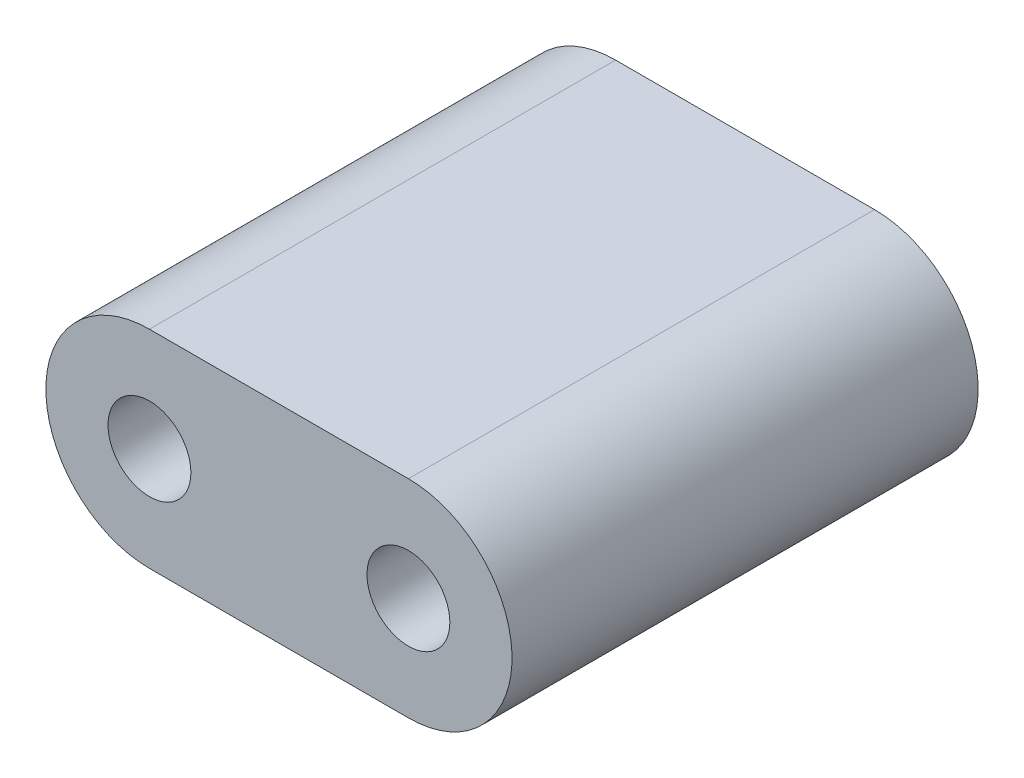
from build123d import *

# Parameters (mm, degrees)
SKETCH1_R           = 1.6
BOSS_EXTRUDE1_DEPTH = 18


with BuildPart() as part:
    # Sketch1 → Boss-Extrude1 (new body)
    with BuildSketch(Plane.XY):
        with BuildLine():
            Line((-5, 4), (5, 4))
            ThreePointArc((5, 4), (9, 0), (5, -4))
            Line((5, -4), (-5, -4))
            ThreePointArc((-5, -4), (-9, 0), (-5, 4))
        make_face()
        with Locations((-5, 0)):
            Circle(SKETCH1_R, mode=Mode.SUBTRACT)
        with Locations((5, 0)):
            Circle(SKETCH1_R, mode=Mode.SUBTRACT)
    extrude(amount=BOSS_EXTRUDE1_DEPTH)


solid = part.part
